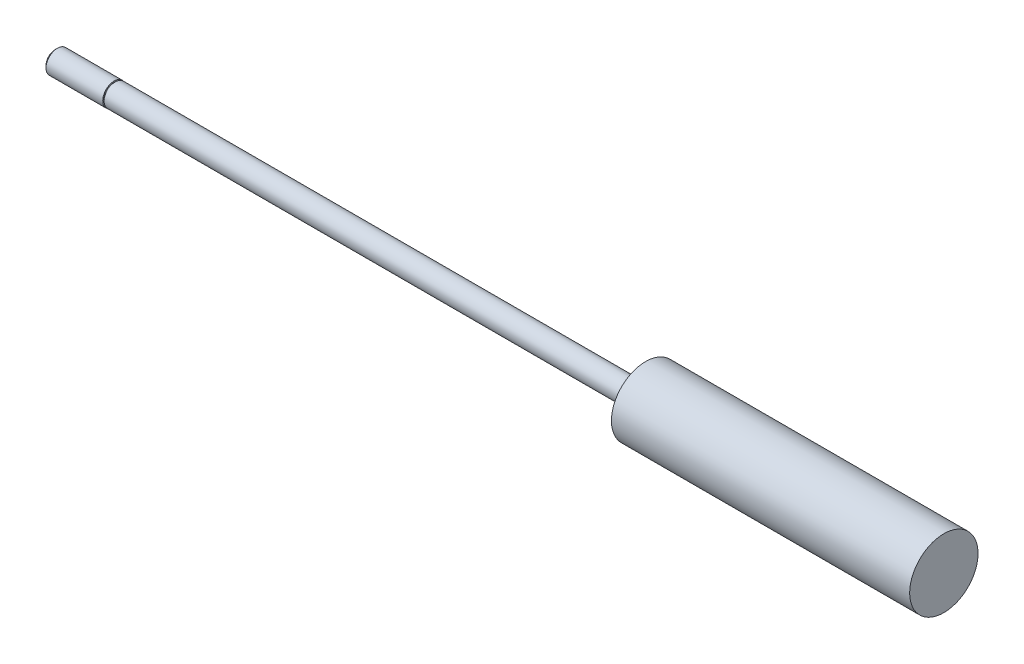
from build123d import *

# Parameters (mm, degrees)
SKETCH3_W = 0.254
SKETCH3_H = 0.508


with BuildPart() as part:
    # Sketch1 → Revolve1 (revolve)
    with BuildSketch(Plane.XY):
        Polygon((0, 0), (0, 2.3749), (111.9124, 2.3749), (111.9124, 7.21995), (174.8536, 7.21995), (174.8536, 0), align=None)
    revolve(axis=Axis((174.8536, 0, 0), (-1, 0, 0)))

    # Sketch2 → Revolve2 (revolve)
    with BuildSketch(Plane.XY):
        Polygon((-12.7, 0), (-12.7, 1.94056), (-12.22756, 2.413), (0, 2.413), (0, 0), align=None)
    revolve(axis=Axis((0, 0, 0), (-1, 0, 0)))

    # Sketch3 → Cut-Revolve1 (revolve, cut)
    with BuildSketch(Plane.XY):
        with Locations((-0.127, 2.413)):
            Rectangle(SKETCH3_W, SKETCH3_H)
    revolve(axis=Axis((0, 0, 0), (-1, 0, 0)), mode=Mode.SUBTRACT)


solid = part.part
